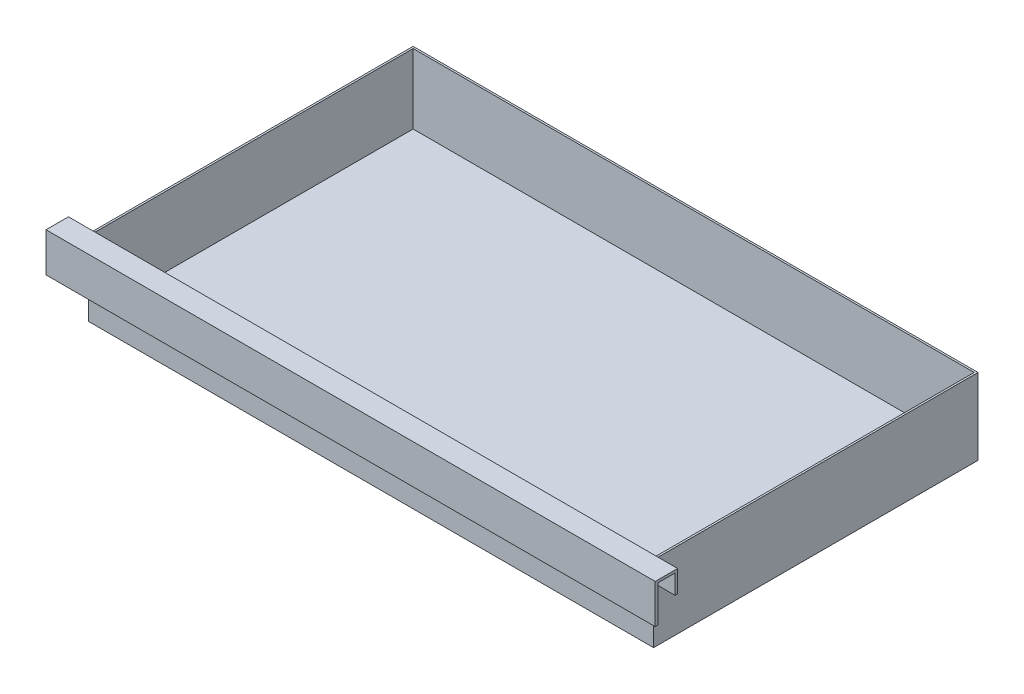
from build123d import *

# Parameters (mm, degrees)
SKETCH1_W         = 223.7486
SKETCH1_H         = 128.4986
BASE_DEPTH        = 2.54
SKETCH1_3_W       = 223.7486
SKETCH1_3_H       = 128.4986
SKETCH1_3_W_2     = 222.25
SKETCH1_3_H_2     = 127
WALLS_DEPTH       = 30.1625
HANDLE_DEPTH      = 120.65
HANDLE_DEPTH_BACK = 120.65


with BuildPart() as part:
    # Sketch1 → Base (new body)
    with BuildSketch(Plane(origin=(0, 0, 0), x_dir=(1, 0, 0), z_dir=(0, 1, 0))):
        with Locations((0, 63.5)):
            Rectangle(SKETCH1_W, SKETCH1_H)
    extrude(amount=BASE_DEPTH)

    # Sketch1_3 → Walls (add)
    with BuildSketch(Plane(origin=(0, 0, 0), x_dir=(1, 0, 0), z_dir=(0, 1, 0))):
        with Locations((0, 63.5)):
            Rectangle(SKETCH1_3_W, SKETCH1_3_H)
        with Locations((0, 63.5)):
            Rectangle(SKETCH1_3_W_2, SKETCH1_3_H_2, mode=Mode.SUBTRACT)
    extrude(amount=WALLS_DEPTH)

    # Sketch2 → Handle (add, two sides: drawn at the far end of the back side and taken through both)
    with BuildSketch(Plane(origin=(0, 0, 0), x_dir=(0, 0, -1), z_dir=(1, 0, 0)).offset(-HANDLE_DEPTH_BACK)):
        Polygon((0, 22.475414602), (0, 31.1785), (-8.89, 31.1785), (-8.89, 15.6845), (-7.874, 15.6845), (-7.874, 30.1625), (-1.016, 30.1625), (-1.016, 22.475414602), align=None)
    extrude(amount=HANDLE_DEPTH + HANDLE_DEPTH_BACK)


solid = part.part
